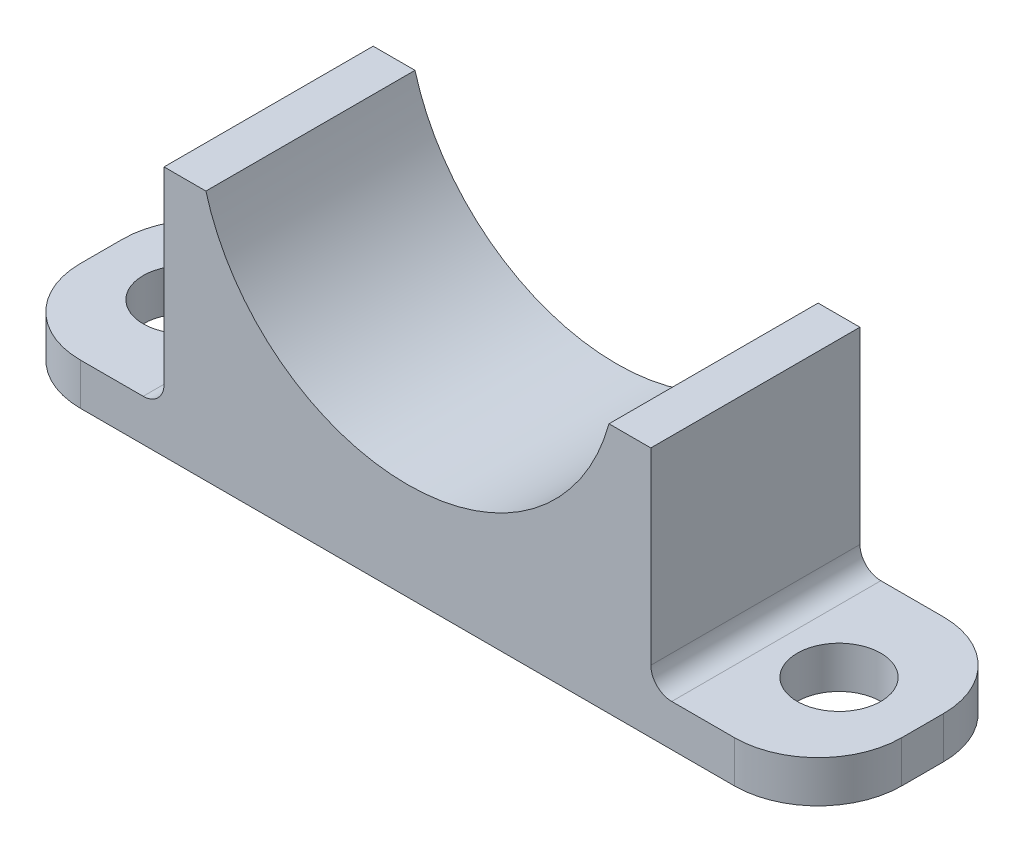
from build123d import *

# Parameters (mm, degrees)
RESSALTO_EXTRUS_O1_DEPTH = 25
ESBO_O3_W                = 25
ESBO_O3_H                = 5
RESSALTO_EXTRUS_O2_DEPTH = 20
FILETE1_R                = 10
FILETE2_R                = 10
ESBO_O4_W                = 25
ESBO_O4_H                = 5
RESSALTO_EXTRUS_O3_DEPTH = 20
FILETE3_R                = 10
FILETE4_R                = 10
ESBO_O5_R                = 5
CORTE_EXTRUS_O1_DEPTH    = 20
FILETE5_R                = 2.5
FILETE6_R                = 2.5


with BuildPart() as part:
    # Esboço2 → Ressalto-extrusão1 (new body)
    with BuildSketch(Plane.XY):
        with BuildLine():
            Line((24.097579721, -6.65632418), (29.097579721, -6.65632418))
            Line((29.097579721, -6.65632418), (29.097579721, -36.65632418))
            Line((29.097579721, -36.65632418), (-29.097579721, -36.65632418))
            Line((-29.097579721, -36.65632418), (-29.097579721, -6.65632418))
            Line((-29.097579721, -6.65632418), (-24.097579721, -6.65632418))
            ThreePointArc((-24.097579721, -6.65632418), (0, -25), (24.097579721, -6.65632418))
        make_face()
    extrude(amount=RESSALTO_EXTRUS_O1_DEPTH)

    # Esboço3 → Ressalto-extrusão2 (add)
    with BuildSketch(Plane.ZY.offset(29.097579721)):
        with Locations((12.5, -34.15632418)):
            Rectangle(ESBO_O3_W, ESBO_O3_H)
    extrude(amount=RESSALTO_EXTRUS_O2_DEPTH)

    # Filete1
    filete1_edges = [part.edges().sort_by_distance(p)[0] for p in [
        (-49.097579721, -34.15632418, 25),
    ]]
    fillet(filete1_edges, radius=FILETE1_R)

    # Filete2
    filete2_edges = [part.edges().sort_by_distance(p)[0] for p in [
        (-49.097579721, -34.15632418, 0),
    ]]
    fillet(filete2_edges, radius=FILETE2_R)

    # Esboço4 → Ressalto-extrusão3 (add)
    with BuildSketch(Plane(origin=(29.097579721, 0, 0), x_dir=(0, 0, -1), z_dir=(1, 0, 0))):
        with Locations((-12.5, -34.15632418)):
            Rectangle(ESBO_O4_W, ESBO_O4_H)
    extrude(amount=RESSALTO_EXTRUS_O3_DEPTH)

    # Filete3
    filete3_edges = [part.edges().sort_by_distance(p)[0] for p in [
        (49.097579721, -34.15632418, 25),
    ]]
    fillet(filete3_edges, radius=FILETE3_R)

    # Filete4
    filete4_edges = [part.edges().sort_by_distance(p)[0] for p in [
        (49.097579721, -34.15632418, 0),
    ]]
    fillet(filete4_edges, radius=FILETE4_R)

    # Esboço5 → Corte-extrusão1 (cut)
    with BuildSketch(Plane(origin=(0, -31.65632418, 0), x_dir=(1, 0, 0), z_dir=(0, 1, 0))):
        with Locations((39.097579721, -12.5)):
            Circle(ESBO_O5_R)
        with Locations((-39.097579721, -12.5)):
            Circle(ESBO_O5_R)
    extrude(amount=-CORTE_EXTRUS_O1_DEPTH, mode=Mode.SUBTRACT)

    # Filete5
    filete5_edges = [part.edges().sort_by_distance(p)[0] for p in [
        (-29.097579721, -31.65632418, 12.5),
    ]]
    fillet(filete5_edges, radius=FILETE5_R)

    # Filete6
    filete6_edges = [part.edges().sort_by_distance(p)[0] for p in [
        (29.097579721, -31.65632418, 12.5),
    ]]
    fillet(filete6_edges, radius=FILETE6_R)


solid = part.part
